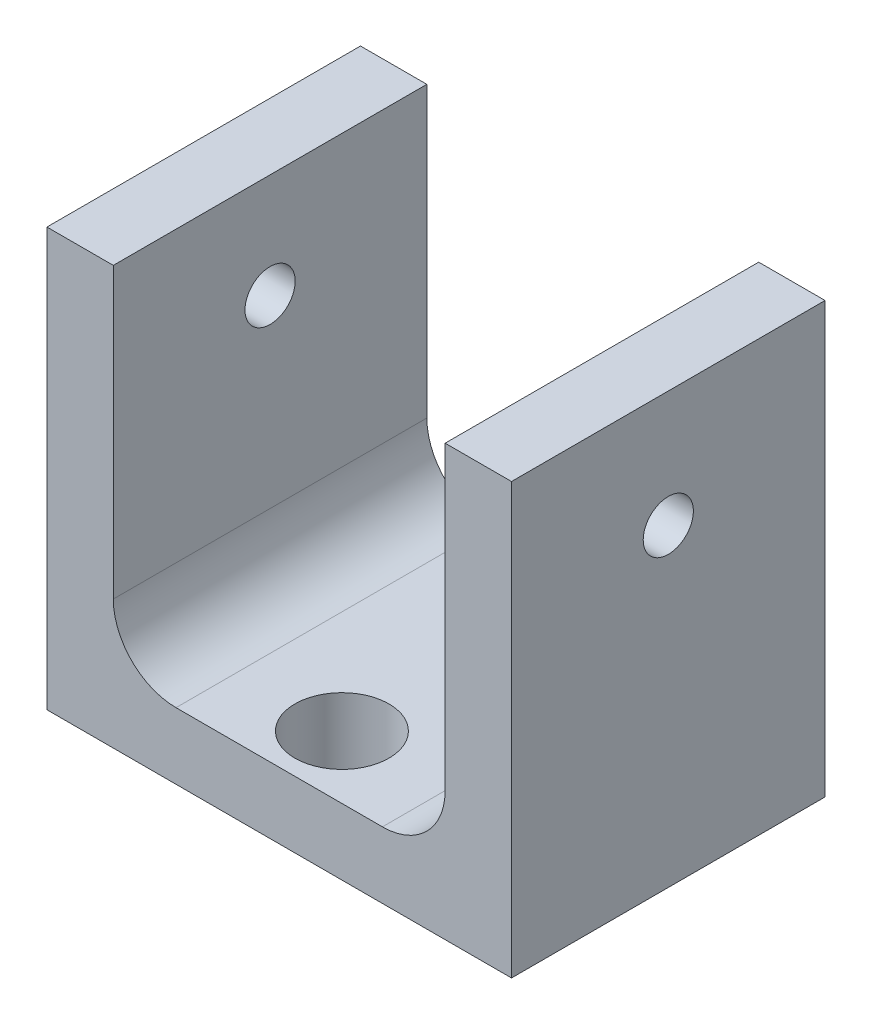
from build123d import *

# Parameters (mm, degrees)
BOSS_EXTRUDE1_DEPTH  = 7.5
M4_CLEARANCE_HOLE1_D = 4.5
M2_CLEARANCE_HOLE1_D = 2.4


with BuildPart() as part:
    # Sketch1 → Boss-Extrude1 (new body, symmetric)
    with BuildSketch(Plane.XY):
        with BuildLine():
            Line((0, 0), (22.225, 0))
            Line((22.225, 0), (22.225, 20.569946809))
            Line((22.225, 20.569946809), (19.05, 20.569946809))
            Line((19.05, 20.569946809), (19.05, 6.175))
            ThreePointArc((19.05, 6.175), (18.171320344, 4.053679656), (16.05, 3.175))
            Line((16.05, 3.175), (6.175, 3.175))
            ThreePointArc((6.175, 3.175), (4.053679656, 4.053679656), (3.175, 6.175))
            Line((3.175, 6.175), (3.175, 20))
            Line((3.175, 20), (0, 20))
            Line((0, 20), (0, 0))
        make_face()
    extrude(amount=BOSS_EXTRUDE1_DEPTH, both=True)

    # M4 Clearance Hole1 (through all)
    with Locations(Plane(origin=(0, 3.175, 0), x_dir=(1, 0, 0), z_dir=(0, 1, 0))):
        with Locations((11.1125, -4.5), (11.1125, 4.5)):
            Hole(M4_CLEARANCE_HOLE1_D / 2)

    # M2 Clearance Hole1 (through all)
    with Locations(Plane.ZY):
        with Locations((0, 15)):
            Hole(M2_CLEARANCE_HOLE1_D / 2)


solid = part.part
